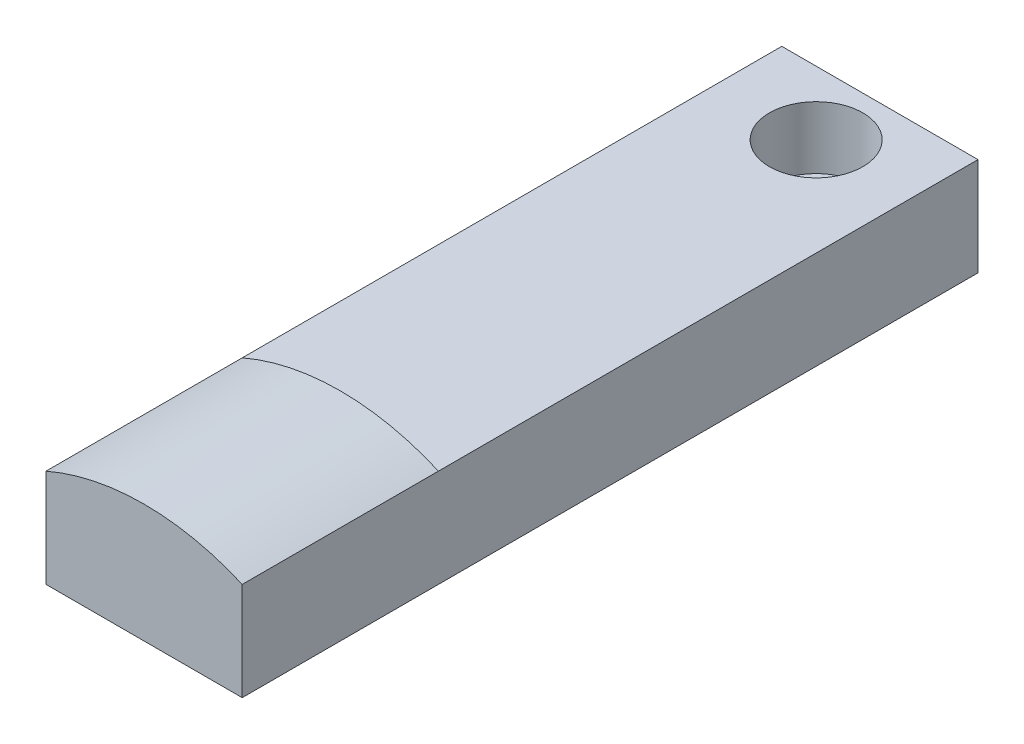
from build123d import *

# Parameters (mm, degrees)
ESBO_O1_W                = 20
ESBO_O1_H                = 10
RESSALTO_EXTRUS_O1_DEPTH = 75
FURO1_D                  = 6.35
FURO1_DEPTH              = 14.916024102
FURO1_CBORE_D            = 9.52
FURO1_CBORE_DEPTH        = 6.35
RESSALTO_EXTRUS_O2_DEPTH = 20


with BuildPart() as part:
    # Esboço1 → Ressalto-extrusão1 (new body)
    with BuildSketch(Plane.XY):
        Rectangle(ESBO_O1_W, ESBO_O1_H)
    extrude(amount=RESSALTO_EXTRUS_O1_DEPTH)

    # Furo1
    with Locations(Plane(origin=(0, 5, 0), x_dir=(1, 0, 0), z_dir=(0, 1, 0))):
        with Locations((0, -6.5)):
            CounterBoreHole(FURO1_D / 2, FURO1_CBORE_D / 2, FURO1_CBORE_DEPTH, depth=FURO1_DEPTH)

    # Esboço4 → Ressalto-extrusão2 (add)
    with BuildSketch(Plane.XY.offset(75)):
        with BuildLine():
            Line((-10, 5), (10, 5))
            ThreePointArc((10, 5), (0, 7.087121525), (-10, 5))
        make_face()
    extrude(amount=-RESSALTO_EXTRUS_O2_DEPTH)


solid = part.part
